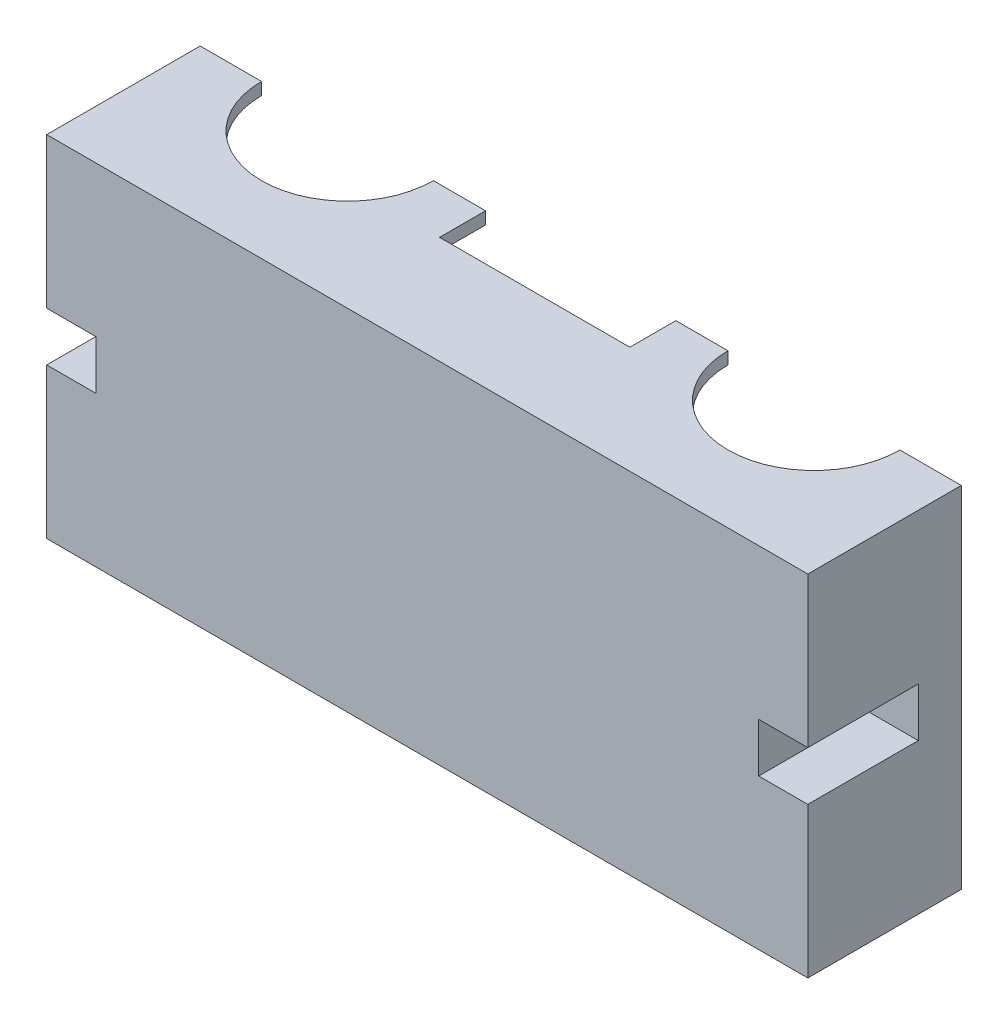
from build123d import *

# Parameters (mm, degrees)
SKIZZE1_W                       = 124
SKIZZE1_H                       = 57
AUFSATZ_LINEAR_AUSTRAGEN1_DEPTH = 25
SKIZZE2_W                       = 8
SKIZZE2_H                       = 8
SCHNITT_LINEAR_AUSTRAGEN4_DEPTH = 18
SKIZZE5_W                       = 120
SKIZZE5_H                       = 20
SKIZZE5_W_2                     = 105
SKIZZE5_H_2                     = 13
SCHNITT_LINEAR_AUSTRAGEN5_DEPTH = 23
SKIZZE6_R                       = 14
SKIZZE6_W                       = 31
SKIZZE6_H                       = 7.5
SCHNITT_LINEAR_AUSTRAGEN6_DEPTH = 2


with BuildPart() as part:
    # Skizze1 → Aufsatz-Linear austragen1 (new body)
    with BuildSketch(Plane.XY):
        with Locations((-40.959148289, 0.914772727)):
            Rectangle(SKIZZE1_W, SKIZZE1_H)
    extrude(amount=AUFSATZ_LINEAR_AUSTRAGEN1_DEPTH)

    # Skizze2 → Schnitt-Linear austragen4 (cut)
    with BuildSketch(Plane.XY.offset(25)):
        with Locations((17.040851711, 0.914772727)):
            Rectangle(SKIZZE2_W, SKIZZE2_H)
        with Locations((-98.959148289, 0.914772727)):
            Rectangle(SKIZZE2_W, SKIZZE2_H)
    extrude(amount=-SCHNITT_LINEAR_AUSTRAGEN4_DEPTH, mode=Mode.SUBTRACT)

    # Skizze5 → Schnitt-Linear austragen5 (cut)
    with BuildSketch(Plane(origin=(0, 0, 0), x_dir=(-1, 0, 0), z_dir=(0, 0, -1))):
        with Locations((40.959148289, 17.414772727)):
            Rectangle(SKIZZE5_W, SKIZZE5_H)
        with Locations((40.959148289, 0.914772727)):
            Rectangle(SKIZZE5_W_2, SKIZZE5_H_2)
        with Locations((40.959148289, -15.585227273)):
            Rectangle(SKIZZE5_W, SKIZZE5_H)
    extrude(amount=-SCHNITT_LINEAR_AUSTRAGEN5_DEPTH, mode=Mode.SUBTRACT)

    # Skizze6 → Schnitt-Linear austragen6 (cut)
    with BuildSketch(Plane(origin=(0, 29.414772727, 0), x_dir=(1, 0, 0), z_dir=(0, 1, 0))):
        with Locations((-2.959148289, 0)):
            Circle(SKIZZE6_R)
        with Locations((-78.959148289, 0)):
            Circle(SKIZZE6_R)
        with Locations((-40.959148289, -3.75)):
            Rectangle(SKIZZE6_W, SKIZZE6_H)
    extrude(amount=-SCHNITT_LINEAR_AUSTRAGEN6_DEPTH, mode=Mode.SUBTRACT)


solid = part.part
